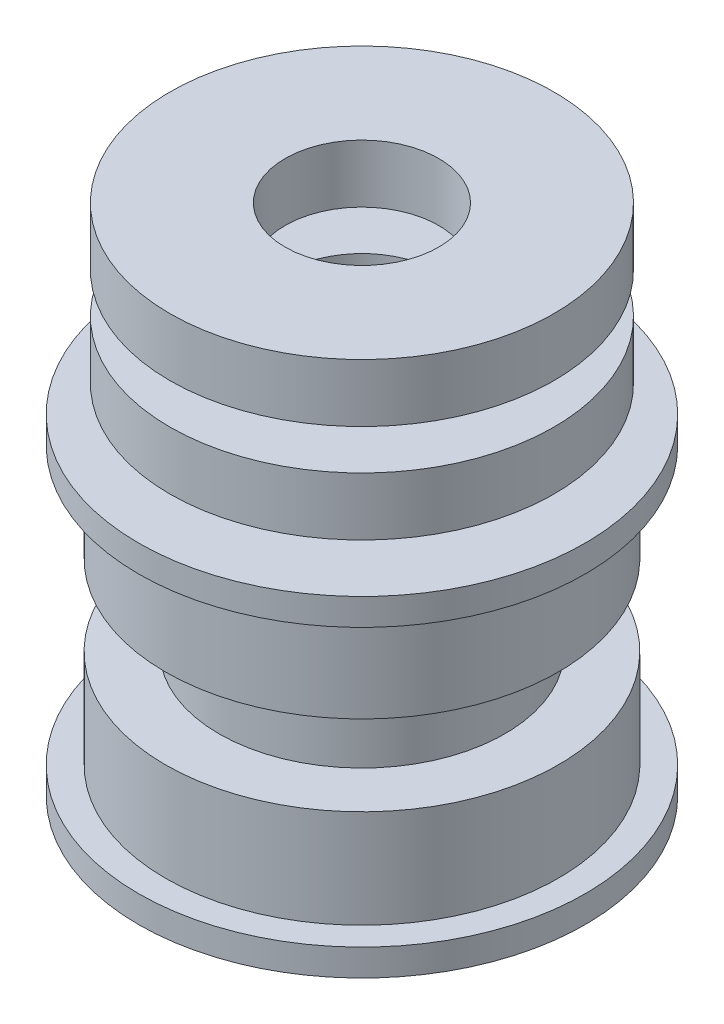
from build123d import *

# Parameters (mm, degrees)
SKETCH1_R           = 12.5
BOSS_EXTRUDE1_DEPTH = 1.5
SKETCH2_R           = 11
BOSS_EXTRUDE2_DEPTH = 5.5
SKETCH3_R           = 8
BOSS_EXTRUDE3_DEPTH = 2.25
SKETCH4_R           = 7.75
BOSS_EXTRUDE4_DEPTH = 1.5
SKETCH5_R           = 10.75
BOSS_EXTRUDE6_DEPTH = 3.25
BOSS_EXTRUDE7_START = 2.25
SKETCH10_R          = 10.75
BOSS_EXTRUDE7_DEPTH = 3.25
SKETCH6_R           = 4.3
CUT_EXTRUDE2_DEPTH  = 50


with BuildPart() as part:
    # Sketch1 → Boss-Extrude1 (new body)
    with BuildSketch(Plane(origin=(0, 0, 0), x_dir=(1, 0, 0), z_dir=(0, 1, 0))):
        Circle(SKETCH1_R)
    extrude(amount=BOSS_EXTRUDE1_DEPTH)

    # Sketch2 → Boss-Extrude2 (add)
    with BuildSketch(Plane(origin=(0, 1.5, 0), x_dir=(1, 0, 0), z_dir=(0, 1, 0))):
        Circle(SKETCH2_R)
    extrude(amount=BOSS_EXTRUDE2_DEPTH)

    # Sketch3 → Boss-Extrude3 (add)
    with BuildSketch(Plane(origin=(0, 7, 0), x_dir=(1, 0, 0), z_dir=(0, 1, 0))):
        Circle(SKETCH3_R)
    extrude(amount=BOSS_EXTRUDE3_DEPTH)

    # Mirror1: part across plane


with BuildPart() as part_1:
    add(part.part)
    add(part.part.mirror(Plane.ZX.offset(9.25)))

    # Sketch4 → Boss-Extrude4 (add)
    with BuildSketch(Plane(origin=(0, 18.5, 0), x_dir=(1, 0, 0), z_dir=(0, 1, 0))):
        Circle(SKETCH4_R)
    extrude(amount=BOSS_EXTRUDE4_DEPTH)

    # Sketch5 → Boss-Extrude6 (add)
    with BuildSketch(Plane(origin=(0, 20, 0), x_dir=(1, 0, 0), z_dir=(0, 1, 0))):
        Circle(SKETCH5_R)
    extrude(amount=BOSS_EXTRUDE6_DEPTH)


with BuildPart() as body_2:
    # Sketch10 → Boss-Extrude7 (new body)
    with BuildSketch(Plane(origin=(0, 23.25, 0), x_dir=(1, 0, 0), z_dir=(0, 1, 0)).offset(BOSS_EXTRUDE7_START)):
        Circle(SKETCH10_R)
    extrude(amount=BOSS_EXTRUDE7_DEPTH)


with BuildPart() as cut_extrude2_tool:
    # Sketch6 → Cut-Extrude2 (new body)
    with BuildSketch(Plane.XZ):
        Circle(SKETCH6_R)
    extrude(amount=-CUT_EXTRUDE2_DEPTH)


with BuildPart() as part_2:
    add(part_1.part)

    # Cut-Extrude2: cut by cut_extrude2_tool
    add(cut_extrude2_tool.part, mode=Mode.SUBTRACT)


with BuildPart() as body_2_1:
    add(body_2.part)

    # Cut-Extrude2: cut by cut_extrude2_tool
    add(cut_extrude2_tool.part, mode=Mode.SUBTRACT)


solid = Compound([part_2.part, body_2_1.part])
